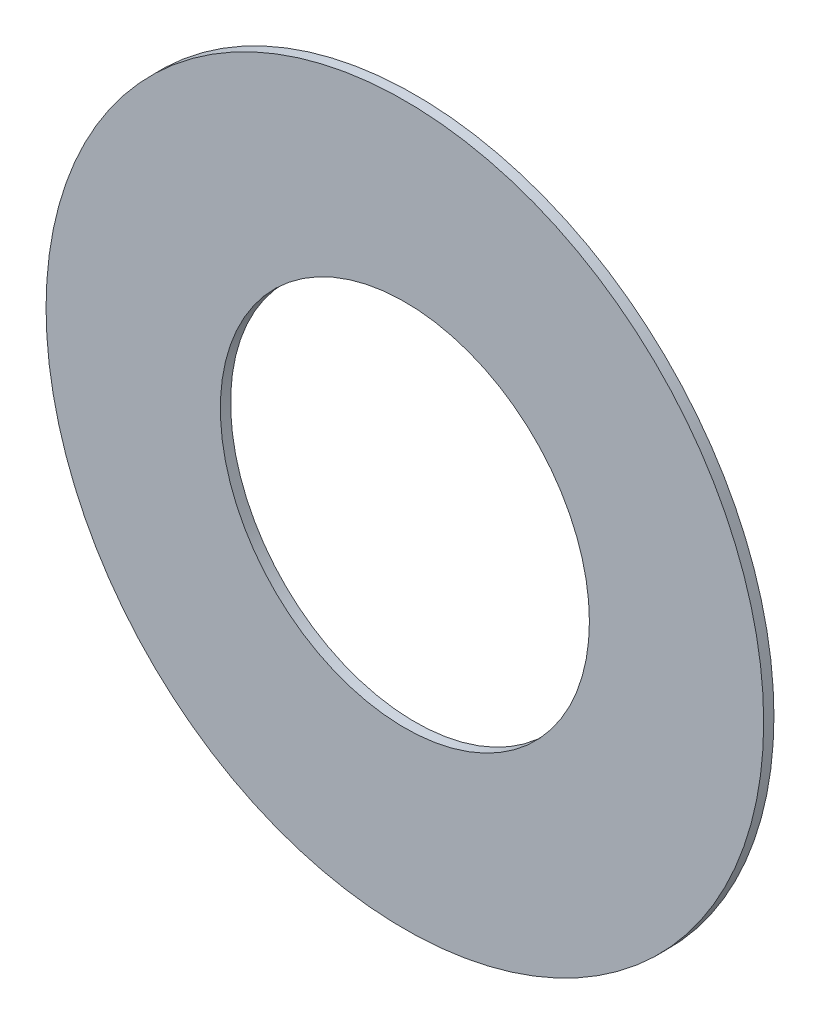
from build123d import *

# Parameters (mm, degrees)
SKETCH1_R           = 70
SKETCH1_R_2         = 36
BOSS_EXTRUDE1_DEPTH = 2
CUT_EXTRUDE1_DEPTH  = 1
CIRPATTERN1_COUNT   = 18


with BuildPart() as part:
    # Sketch1 → Boss-Extrude1 (new body)
    with BuildSketch(Plane.XY):
        Circle(SKETCH1_R)
        Circle(SKETCH1_R_2, mode=Mode.SUBTRACT)
    extrude(amount=BOSS_EXTRUDE1_DEPTH)

    # Sketch2 → Cut-Extrude1 (cut)
    with BuildSketch(Plane.XY):
        with BuildLine():
            Line((-41, 40.5), (3, 40.5))
            ThreePointArc((3, 40.5), (3.5, 40), (3, 39.5))
            Line((3, 39.5), (-41, 39.5))
            ThreePointArc((-41, 39.5), (-41.5, 40), (-41, 40.5))
        make_face()
    cut_extrude1 = extrude(amount=CUT_EXTRUDE1_DEPTH, mode=Mode.SUBTRACT)

    # CirPattern1: Cut-Extrude1 ×18 about axis
    cirpattern1_axis = Axis((0, 0, 0), (0, 0, 1))
    for i in range(1, CIRPATTERN1_COUNT):
        add(cut_extrude1.rotate(cirpattern1_axis, i * 360 / CIRPATTERN1_COUNT), mode=Mode.SUBTRACT)


solid = part.part
